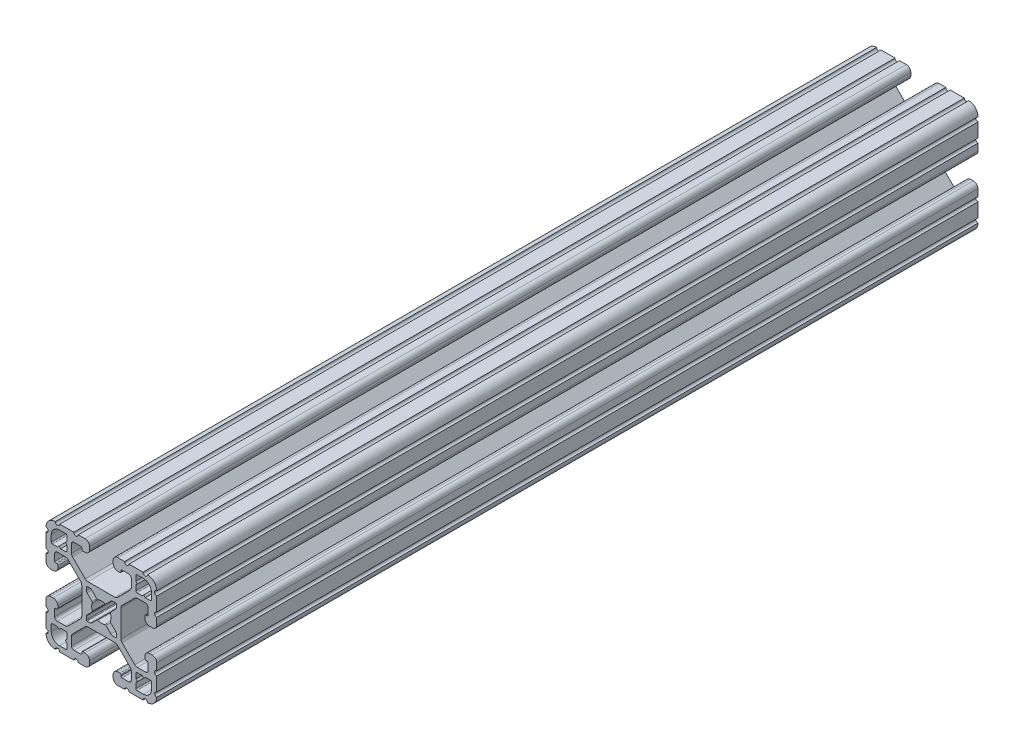
from build123d import *

# Parameters (mm, degrees)
BOSS_EXTRUDE1_DEPTH = 282.575


with BuildPart() as part:
    # Sketch1 → Boss-Extrude1 (new body)
    with BuildSketch(Plane(origin=(0, 0, -2322.576), x_dir=(-1, 0, 0), z_dir=(0, 0, -1))):
        with BuildLine():
            Line((19.05, -14.325600033), (19.05, -9.4996))
            ThreePointArc((19.05, -9.4996), (18.288, -8.7376), (19.05, -7.9756))
            Line((19.05, -7.9756), (19.05, -5.6388))
            ThreePointArc((19.05, -5.6388), (18.588751759, -4.525248241), (17.4752, -4.064))
            Line((17.4752, -4.064), (16.5608, -4.064))
            ThreePointArc((16.5608, -4.064), (15.447248241, -4.525248241), (14.986, -5.6388))
            Line((14.986, -5.6388), (14.986, -6.350014224))
            ThreePointArc((14.986, -6.350014224), (15.097592316, -6.619421908), (15.367, -6.731014224))
            Line((15.367, -6.731014224), (15.6972, -6.731014224))
            ThreePointArc((15.6972, -6.731014224), (15.966607684, -6.84260654), (16.0782, -7.112014224))
            Line((16.0782, -7.112014224), (16.0782, -9.398014224))
            ThreePointArc((16.0782, -9.398014224), (15.817817928, -10.026632152), (15.1892, -10.287014224))
            Line((15.1892, -10.287014224), (12.375630013, -10.287014224))
            ThreePointArc((12.375630013, -10.287014224), (11.889622054, -10.19034123), (11.477604401, -9.915039836))
            Line((11.477604401, -9.915039836), (7.115699788, -5.553135223))
            ThreePointArc((7.115699788, -5.553135223), (6.840398394, -5.14111757), (6.7437254, -4.655109611))
            Line((6.7437254, -4.655109611), (6.7437254, 4.655109611))
            ThreePointArc((6.7437254, 4.655109611), (6.840398394, 5.14111757), (7.115699788, 5.553135223))
            Line((7.115699788, 5.553135223), (11.477604401, 9.915039836))
            ThreePointArc((11.477604401, 9.915039836), (11.889622054, 10.19034123), (12.375630013, 10.287014224))
            Line((12.375630013, 10.287014224), (15.1892, 10.287014224))
            ThreePointArc((15.1892, 10.287014224), (15.817817928, 10.026632152), (16.0782, 9.398014224))
            Line((16.0782, 9.398014224), (16.0782, 7.112014224))
            ThreePointArc((16.0782, 7.112014224), (15.966607684, 6.84260654), (15.6972, 6.731014224))
            Line((15.6972, 6.731014224), (15.367, 6.731014224))
            ThreePointArc((15.367, 6.731014224), (15.097592316, 6.619421908), (14.986, 6.350014224))
            Line((14.986, 6.350014224), (14.986, 5.6388))
            ThreePointArc((14.986, 5.6388), (15.447248241, 4.525248241), (16.5608, 4.064))
            Line((16.5608, 4.064), (17.4752, 4.064))
            ThreePointArc((17.4752, 4.064), (18.588751759, 4.525248241), (19.05, 5.6388))
            Line((19.05, 5.6388), (19.05, 7.9756))
            ThreePointArc((19.05, 7.9756), (18.288, 8.7376), (19.05, 9.4996))
            Line((19.05, 9.4996), (19.05, 14.325599984))
            ThreePointArc((19.05, 14.325599984), (18.287999986, 15.087549208), (19.049898416, 15.849600009))
            ThreePointArc((19.049898416, 15.849600009), (18.120064036, 18.120064058), (15.849599977, 19.049898414))
            ThreePointArc((15.849599977, 19.049898414), (15.0875492, 18.288000035), (14.325600017, 19.050000016))
            Line((14.325600017, 19.050000016), (9.499600001, 19.050000016))
            ThreePointArc((9.499600001, 19.050000016), (8.737600001, 18.288000016), (7.975600001, 19.050000016))
            Line((7.975600001, 19.050000016), (5.638800016, 19.050000016))
            ThreePointArc((5.638800016, 19.050000016), (4.525248257, 18.588751775), (4.064000016, 17.475200016))
            Line((4.064000016, 17.475200016), (4.064000016, 16.5608))
            ThreePointArc((4.064000016, 16.5608), (4.525248257, 15.447248241), (5.638800016, 14.986))
            Line((5.638800016, 14.986), (6.350014224, 14.986))
            ThreePointArc((6.350014224, 14.986), (6.619421908, 15.097592316), (6.731014224, 15.367))
            Line((6.731014224, 15.367), (6.731014224, 15.6972))
            ThreePointArc((6.731014224, 15.6972), (6.84260654, 15.966607684), (7.112014224, 16.0782))
            Line((7.112014224, 16.0782), (9.398014224, 16.0782))
            ThreePointArc((9.398014224, 16.0782), (10.026632152, 15.817817928), (10.287014224, 15.1892))
            Line((10.287014224, 15.1892), (10.287014224, 12.375630013))
            ThreePointArc((10.287014224, 12.375630013), (10.19034123, 11.889622054), (9.915039836, 11.477604401))
            Line((9.915039836, 11.477604401), (5.553135223, 7.115699788))
            ThreePointArc((5.553135223, 7.115699788), (5.14111757, 6.840398394), (4.655109611, 6.7437254))
            Line((4.655109611, 6.7437254), (-4.655109611, 6.7437254))
            ThreePointArc((-4.655109611, 6.7437254), (-5.14111757, 6.840398394), (-5.553135223, 7.115699788))
            Line((-5.553135223, 7.115699788), (-9.915039836, 11.477604401))
            ThreePointArc((-9.915039836, 11.477604401), (-10.19034123, 11.889622054), (-10.287014224, 12.375630013))
            Line((-10.287014224, 12.375630013), (-10.287014224, 15.1892))
            ThreePointArc((-10.287014224, 15.1892), (-10.026632152, 15.817817928), (-9.398014224, 16.0782))
            Line((-9.398014224, 16.0782), (-7.112014224, 16.0782))
            ThreePointArc((-7.112014224, 16.0782), (-6.84260654, 15.966607684), (-6.731014224, 15.6972))
            Line((-6.731014224, 15.6972), (-6.731014224, 15.367))
            ThreePointArc((-6.731014224, 15.367), (-6.619421908, 15.097592316), (-6.350014224, 14.986))
            Line((-6.350014224, 14.986), (-5.638799984, 14.986))
            ThreePointArc((-5.638799984, 14.986), (-4.525248225, 15.447248241), (-4.063999984, 16.5608))
            Line((-4.063999984, 16.5608), (-4.063999984, 17.475200016))
            ThreePointArc((-4.063999984, 17.475200016), (-4.525248225, 18.588751775), (-5.638799984, 19.050000016))
            Line((-5.638799984, 19.050000016), (-7.975599999, 19.050000016))
            ThreePointArc((-7.975599999, 19.050000016), (-8.737599999, 18.288000016), (-9.499599999, 19.050000016))
            Line((-9.499599999, 19.050000016), (-14.325599999, 19.050000016))
            ThreePointArc((-14.325599999, 19.050000016), (-15.087549199, 18.288000018), (-15.849599993, 19.049898416))
            ThreePointArc((-15.849599993, 19.049898416), (-18.120064042, 18.120064036), (-19.049898398, 15.849599976))
            ThreePointArc((-19.049898398, 15.849599976), (-18.288000019, 15.087549199), (-19.05, 14.325600017))
            Line((-19.05, 14.325600017), (-19.05, 9.4996))
            ThreePointArc((-19.05, 9.4996), (-18.288, 8.7376), (-19.05, 7.9756))
            Line((-19.05, 7.9756), (-19.05, 5.6388))
            ThreePointArc((-19.05, 5.6388), (-18.588751759, 4.525248241), (-17.4752, 4.064))
            Line((-17.4752, 4.064), (-16.5608, 4.064))
            ThreePointArc((-16.5608, 4.064), (-15.447248241, 4.525248241), (-14.986, 5.6388))
            Line((-14.986, 5.6388), (-14.986, 6.350014224))
            ThreePointArc((-14.986, 6.350014224), (-15.097592316, 6.619421908), (-15.367, 6.731014224))
            Line((-15.367, 6.731014224), (-15.6972, 6.731014224))
            ThreePointArc((-15.6972, 6.731014224), (-15.966607684, 6.84260654), (-16.0782, 7.112014224))
            Line((-16.0782, 7.112014224), (-16.0782, 9.398014224))
            ThreePointArc((-16.0782, 9.398014224), (-15.817817928, 10.026632152), (-15.1892, 10.287014224))
            Line((-15.1892, 10.287014224), (-12.375630013, 10.287014224))
            ThreePointArc((-12.375630013, 10.287014224), (-11.889622054, 10.19034123), (-11.477604401, 9.915039836))
            Line((-11.477604401, 9.915039836), (-7.115699788, 5.553135223))
            ThreePointArc((-7.115699788, 5.553135223), (-6.840398394, 5.14111757), (-6.7437254, 4.655109611))
            Line((-6.7437254, 4.655109611), (-6.7437254, -4.655109611))
            ThreePointArc((-6.7437254, -4.655109611), (-6.840398394, -5.14111757), (-7.115699788, -5.553135223))
            Line((-7.115699788, -5.553135223), (-11.477604401, -9.915039836))
            ThreePointArc((-11.477604401, -9.915039836), (-11.889622054, -10.19034123), (-12.375630013, -10.287014224))
            Line((-12.375630013, -10.287014224), (-15.1892, -10.287014224))
            ThreePointArc((-15.1892, -10.287014224), (-15.817817928, -10.026632152), (-16.0782, -9.398014224))
            Line((-16.0782, -9.398014224), (-16.0782, -7.112014224))
            ThreePointArc((-16.0782, -7.112014224), (-15.966607684, -6.84260654), (-15.6972, -6.731014224))
            Line((-15.6972, -6.731014224), (-15.367, -6.731014224))
            ThreePointArc((-15.367, -6.731014224), (-15.097592316, -6.619421908), (-14.986, -6.350014224))
            Line((-14.986, -6.350014224), (-14.986, -5.6388))
            ThreePointArc((-14.986, -5.6388), (-15.447248241, -4.525248241), (-16.5608, -4.064))
            Line((-16.5608, -4.064), (-17.4752, -4.064))
            ThreePointArc((-17.4752, -4.064), (-18.588751759, -4.525248241), (-19.05, -5.6388))
            Line((-19.05, -5.6388), (-19.05, -7.9756))
            ThreePointArc((-19.05, -7.9756), (-18.288, -8.7376), (-19.05, -9.4996))
            Line((-19.05, -9.4996), (-19.05, -14.3256))
            ThreePointArc((-19.05, -14.3256), (-18.288000002, -15.0875492), (-19.0498984, -15.849599993))
            ThreePointArc((-19.0498984, -15.849599993), (-18.120064019, -18.120064043), (-15.84959996, -19.049898399))
            ThreePointArc((-15.84959996, -19.049898399), (-15.087549183, -18.288000019), (-14.325600001, -19.050000001))
            Line((-14.325600001, -19.050000001), (-9.499599984, -19.050000001))
            ThreePointArc((-9.499599984, -19.050000001), (-8.737599984, -18.288000001), (-7.975599984, -19.050000001))
            Line((-7.975599984, -19.050000001), (-5.638799984, -19.050000001))
            ThreePointArc((-5.638799984, -19.050000001), (-4.525248225, -18.58875176), (-4.063999984, -17.475200001))
            Line((-4.063999984, -17.475200001), (-4.063999984, -16.5608))
            ThreePointArc((-4.063999984, -16.5608), (-4.525248225, -15.447248241), (-5.638799984, -14.986))
            Line((-5.638799984, -14.986), (-6.350014224, -14.986))
            ThreePointArc((-6.350014224, -14.986), (-6.619421908, -15.097592316), (-6.731014224, -15.367))
            Line((-6.731014224, -15.367), (-6.731014224, -15.6972))
            ThreePointArc((-6.731014224, -15.6972), (-6.84260654, -15.966607684), (-7.112014224, -16.0782))
            Line((-7.112014224, -16.0782), (-9.398014224, -16.0782))
            ThreePointArc((-9.398014224, -16.0782), (-10.026632152, -15.817817928), (-10.287014224, -15.1892))
            Line((-10.287014224, -15.1892), (-10.287014224, -12.375630013))
            ThreePointArc((-10.287014224, -12.375630013), (-10.19034123, -11.889622054), (-9.915039836, -11.477604401))
            Line((-9.915039836, -11.477604401), (-5.553135223, -7.115699788))
            ThreePointArc((-5.553135223, -7.115699788), (-5.14111757, -6.840398394), (-4.655109611, -6.7437254))
            Line((-4.655109611, -6.7437254), (4.655109611, -6.7437254))
            ThreePointArc((4.655109611, -6.7437254), (5.14111757, -6.840398394), (5.553135223, -7.115699788))
            Line((5.553135223, -7.115699788), (9.915039836, -11.477604401))
            ThreePointArc((9.915039836, -11.477604401), (10.19034123, -11.889622054), (10.287014224, -12.375630013))
            Line((10.287014224, -12.375630013), (10.287014224, -15.1892))
            ThreePointArc((10.287014224, -15.1892), (10.026632152, -15.817817928), (9.398014224, -16.0782))
            Line((9.398014224, -16.0782), (7.112014224, -16.0782))
            ThreePointArc((7.112014224, -16.0782), (6.84260654, -15.966607684), (6.731014224, -15.6972))
            Line((6.731014224, -15.6972), (6.731014224, -15.367))
            ThreePointArc((6.731014224, -15.367), (6.619421908, -15.097592316), (6.350014224, -14.986))
            Line((6.350014224, -14.986), (5.638800016, -14.986))
            ThreePointArc((5.638800016, -14.986), (4.525248257, -15.447248241), (4.064000016, -16.5608))
            Line((4.064000016, -16.5608), (4.064000016, -17.475200001))
            ThreePointArc((4.064000016, -17.475200001), (4.525248257, -18.58875176), (5.638800016, -19.050000001))
            Line((5.638800016, -19.050000001), (7.975600016, -19.050000001))
            ThreePointArc((7.975600016, -19.050000001), (8.737600016, -18.288000001), (9.499600016, -19.050000001))
            Line((9.499600016, -19.050000001), (14.325600016, -19.050000001))
            ThreePointArc((14.325600016, -19.050000001), (15.087549216, -18.288000002), (15.849600009, -19.0498984))
            ThreePointArc((15.849600009, -19.0498984), (18.120064059, -18.12006402), (19.049898415, -15.849599961))
            ThreePointArc((19.049898415, -15.849599961), (18.288000034, -15.087549207), (19.05, -14.325600033))
        make_face()
        with BuildLine():
            Line((17.246614224, 14.452614224), (17.246614224, 12.242814224))
            ThreePointArc((17.246614224, 12.242814224), (17.135021908, 11.97340654), (16.865614224, 11.861814224))
            Line((16.865614224, 11.861814224), (15.092694224, 11.861814224))
            Line((15.092694224, 11.861814224), (14.554214224, 12.400294224))
            Line((14.554214224, 12.400294224), (14.015734224, 11.861814224))
            Line((14.015734224, 11.861814224), (12.242814224, 11.861814224))
            ThreePointArc((12.242814224, 11.861814224), (11.97340654, 11.97340654), (11.861814224, 12.242814224))
            Line((11.861814224, 12.242814224), (11.861814224, 14.015734224))
            Line((11.861814224, 14.015734224), (12.400294224, 14.554214224))
            Line((12.400294224, 14.554214224), (11.861814224, 15.092694224))
            Line((11.861814224, 15.092694224), (11.861814224, 16.865614224))
            ThreePointArc((11.861814224, 16.865614224), (11.97340654, 17.135021908), (12.242814224, 17.246614224))
            Line((12.242814224, 17.246614224), (14.452614224, 17.246614224))
            ThreePointArc((14.452614224, 17.246614224), (16.428270571, 16.428270571), (17.246614224, 14.452614224))
        make_face(mode=Mode.SUBTRACT)
        with BuildLine():
            Line((17.246614224, -12.242814224), (17.246614224, -14.452614224))
            ThreePointArc((17.246614224, -14.452614224), (16.428270571, -16.428270571), (14.452614224, -17.246614224))
            Line((14.452614224, -17.246614224), (12.242814224, -17.246614224))
            ThreePointArc((12.242814224, -17.246614224), (11.97340654, -17.135021908), (11.861814224, -16.865614224))
            Line((11.861814224, -16.865614224), (11.861814224, -15.092694224))
            Line((11.861814224, -15.092694224), (12.400294224, -14.554214224))
            Line((12.400294224, -14.554214224), (11.861814224, -14.015734224))
            Line((11.861814224, -14.015734224), (11.861814224, -12.242814224))
            ThreePointArc((11.861814224, -12.242814224), (11.97340654, -11.97340654), (12.242814224, -11.861814224))
            Line((12.242814224, -11.861814224), (14.015734224, -11.861814224))
            Line((14.015734224, -11.861814224), (14.554214224, -12.400294224))
            Line((14.554214224, -12.400294224), (15.092694224, -11.861814224))
            Line((15.092694224, -11.861814224), (16.865614224, -11.861814224))
            ThreePointArc((16.865614224, -11.861814224), (17.135021908, -11.97340654), (17.246614224, -12.242814224))
        make_face(mode=Mode.SUBTRACT)
        with BuildLine():
            Line((5.1689, -3.920689755), (5.1689, -4.9149))
            ThreePointArc((5.1689, -4.9149), (5.094505122, -5.094505122), (4.9149, -5.1689))
            Line((4.9149, -5.1689), (3.920689755, -5.1689))
            ThreePointArc((3.920689755, -5.1689), (3.580484184, -5.101228904), (3.292071827, -4.908517928))
            Line((3.292071827, -4.908517928), (1.582347442, -3.198793543))
            ThreePointArc((1.582347442, -3.198793543), (1.393016011, -3.095711236), (1.178048687, -3.111879183))
            ThreePointArc((1.178048687, -3.111879183), (0, -3.3274), (-1.178048687, -3.111879183))
            ThreePointArc((-1.178048687, -3.111879183), (-1.393016011, -3.095711236), (-1.582347442, -3.198793543))
            Line((-1.582347442, -3.198793543), (-3.292071827, -4.908517928))
            ThreePointArc((-3.292071827, -4.908517928), (-3.580484184, -5.101228904), (-3.920689755, -5.1689))
            Line((-3.920689755, -5.1689), (-4.9149, -5.1689))
            ThreePointArc((-4.9149, -5.1689), (-5.094505122, -5.094505122), (-5.1689, -4.9149))
            Line((-5.1689, -4.9149), (-5.1689, -3.920689755))
            ThreePointArc((-5.1689, -3.920689755), (-5.101228904, -3.580484184), (-4.908517928, -3.292071827))
            Line((-4.908517928, -3.292071827), (-3.198793543, -1.582347442))
            ThreePointArc((-3.198793543, -1.582347442), (-3.095711236, -1.393016011), (-3.111879183, -1.178048687))
            ThreePointArc((-3.111879183, -1.178048687), (-3.3274, 0), (-3.111879183, 1.178048687))
            ThreePointArc((-3.111879183, 1.178048687), (-3.095711236, 1.393016011), (-3.198793543, 1.582347442))
            Line((-3.198793543, 1.582347442), (-4.908517928, 3.292071827))
            ThreePointArc((-4.908517928, 3.292071827), (-5.101228904, 3.580484184), (-5.1689, 3.920689755))
            Line((-5.1689, 3.920689755), (-5.1689, 4.9149))
            ThreePointArc((-5.1689, 4.9149), (-5.094505122, 5.094505122), (-4.9149, 5.1689))
            Line((-4.9149, 5.1689), (-3.920689755, 5.1689))
            ThreePointArc((-3.920689755, 5.1689), (-3.580484184, 5.101228904), (-3.292071827, 4.908517928))
            Line((-3.292071827, 4.908517928), (-1.582347442, 3.198793543))
            ThreePointArc((-1.582347442, 3.198793543), (-1.393016011, 3.095711236), (-1.178048687, 3.111879183))
            ThreePointArc((-1.178048687, 3.111879183), (0, 3.3274), (1.178048687, 3.111879183))
            ThreePointArc((1.178048687, 3.111879183), (1.393016011, 3.095711236), (1.582347442, 3.198793543))
            Line((1.582347442, 3.198793543), (3.292071827, 4.908517928))
            ThreePointArc((3.292071827, 4.908517928), (3.580484184, 5.101228904), (3.920689755, 5.1689))
            Line((3.920689755, 5.1689), (4.9149, 5.1689))
            ThreePointArc((4.9149, 5.1689), (5.094505122, 5.094505122), (5.1689, 4.9149))
            Line((5.1689, 4.9149), (5.1689, 3.920689755))
            ThreePointArc((5.1689, 3.920689755), (5.101228904, 3.580484184), (4.908517928, 3.292071827))
            Line((4.908517928, 3.292071827), (3.198793543, 1.582347442))
            ThreePointArc((3.198793543, 1.582347442), (3.095711236, 1.393016011), (3.111879183, 1.178048687))
            ThreePointArc((3.111879183, 1.178048687), (3.3274, 0), (3.111879183, -1.178048687))
            ThreePointArc((3.111879183, -1.178048687), (3.095711236, -1.393016011), (3.198793543, -1.582347442))
            Line((3.198793543, -1.582347442), (4.908517928, -3.292071827))
            ThreePointArc((4.908517928, -3.292071827), (5.101228904, -3.580484184), (5.1689, -3.920689755))
        make_face(mode=Mode.SUBTRACT)
        with BuildLine():
            Line((-11.861814224, -12.242814224), (-11.861814224, -14.015734224))
            Line((-11.861814224, -14.015734224), (-12.400294224, -14.554214224))
            Line((-12.400294224, -14.554214224), (-11.861814224, -15.092694224))
            Line((-11.861814224, -15.092694224), (-11.861814224, -16.865614224))
            ThreePointArc((-11.861814224, -16.865614224), (-11.97340654, -17.135021908), (-12.242814224, -17.246614224))
            Line((-12.242814224, -17.246614224), (-14.452614224, -17.246614224))
            ThreePointArc((-14.452614224, -17.246614224), (-16.428270571, -16.428270571), (-17.246614224, -14.452614224))
            Line((-17.246614224, -14.452614224), (-17.246614224, -12.242814224))
            ThreePointArc((-17.246614224, -12.242814224), (-17.135021908, -11.97340654), (-16.865614224, -11.861814224))
            Line((-16.865614224, -11.861814224), (-15.092694224, -11.861814224))
            Line((-15.092694224, -11.861814224), (-14.554214224, -12.400294224))
            Line((-14.554214224, -12.400294224), (-14.015734224, -11.861814224))
            Line((-14.015734224, -11.861814224), (-12.242814224, -11.861814224))
            ThreePointArc((-12.242814224, -11.861814224), (-11.97340654, -11.97340654), (-11.861814224, -12.242814224))
        make_face(mode=Mode.SUBTRACT)
        with BuildLine():
            Line((-11.861814224, 16.865614224), (-11.861814224, 15.092694224))
            Line((-11.861814224, 15.092694224), (-12.400294224, 14.554214224))
            Line((-12.400294224, 14.554214224), (-11.861814224, 14.015734224))
            Line((-11.861814224, 14.015734224), (-11.861814224, 12.242814224))
            ThreePointArc((-11.861814224, 12.242814224), (-11.97340654, 11.97340654), (-12.242814224, 11.861814224))
            Line((-12.242814224, 11.861814224), (-14.015734224, 11.861814224))
            Line((-14.015734224, 11.861814224), (-14.554214224, 12.400294224))
            Line((-14.554214224, 12.400294224), (-15.092694224, 11.861814224))
            Line((-15.092694224, 11.861814224), (-16.865614224, 11.861814224))
            ThreePointArc((-16.865614224, 11.861814224), (-17.135021908, 11.97340654), (-17.246614224, 12.242814224))
            Line((-17.246614224, 12.242814224), (-17.246614224, 14.452614224))
            ThreePointArc((-17.246614224, 14.452614224), (-16.428270571, 16.428270571), (-14.452614224, 17.246614224))
            Line((-14.452614224, 17.246614224), (-12.242814224, 17.246614224))
            ThreePointArc((-12.242814224, 17.246614224), (-11.97340654, 17.135021908), (-11.861814224, 16.865614224))
        make_face(mode=Mode.SUBTRACT)
    extrude(amount=-BOSS_EXTRUDE1_DEPTH)


solid = part.part
